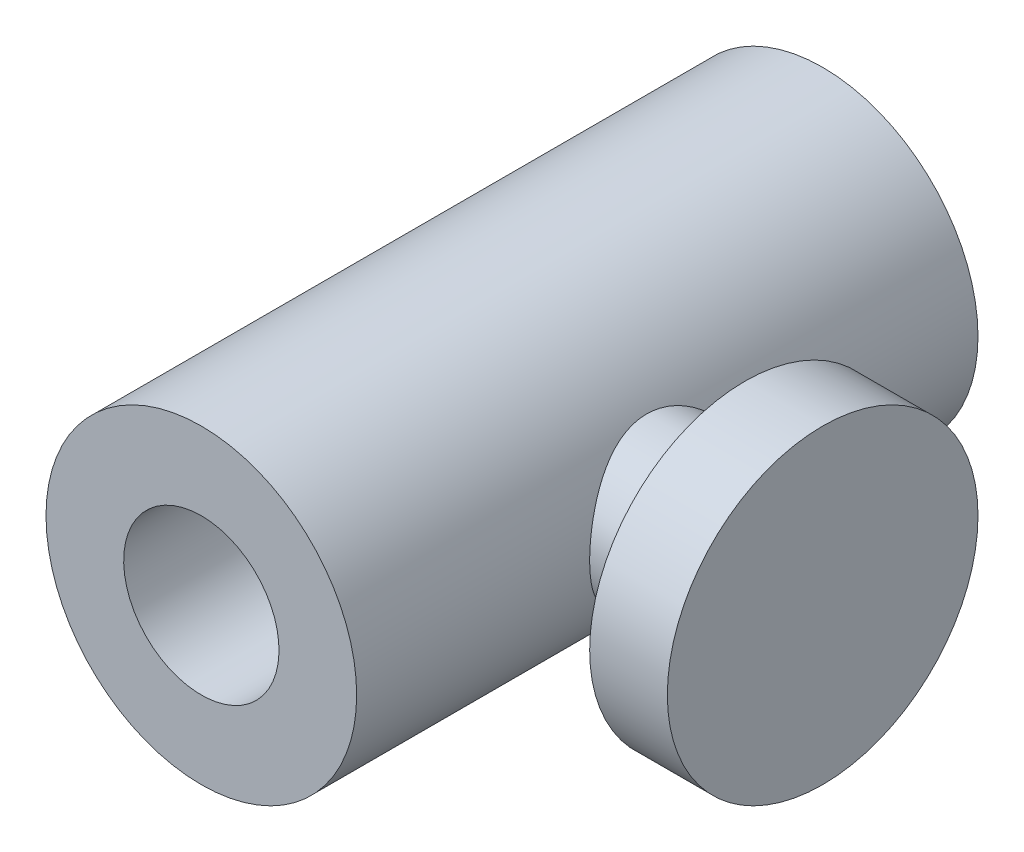
from build123d import *

# Parameters (mm, degrees)
SKETCH1_W                      = 10
SKETCH1_H                      = 40
F_10_0_10_DIAMETER_HOLE1_D     = 10
F_10_0_10_DIAMETER_HOLE1_DEPTH = 40


with BuildPart() as part:
    # Sketch1 → Revolve1 (revolve)
    with BuildSketch(Plane.XZ):
        with Locations((5, 20)):
            Rectangle(SKETCH1_W, SKETCH1_H)
    revolve(axis=Axis((0, 0, 40), (0, 0, -1)))

    # Sketch2 → Revolve2 (revolve)
    with BuildSketch(Plane.XY.offset(20)):
        Polygon((20, 0), (20, 10), (15, 10), (15, 5), (8.660254038, 5), (8.660254038, 0), align=None)
    revolve(axis=Axis((8.660254038, 0, 20), (1, 0, 0)))

    # Ø10.0 (10) Diameter Hole1
    with Locations(Plane(origin=(0, 0, 0), x_dir=(-1, 0, 0), z_dir=(0, 0, -1))):
        with Locations((0, 0)):
            Hole(F_10_0_10_DIAMETER_HOLE1_D / 2, depth=F_10_0_10_DIAMETER_HOLE1_DEPTH)


solid = part.part
